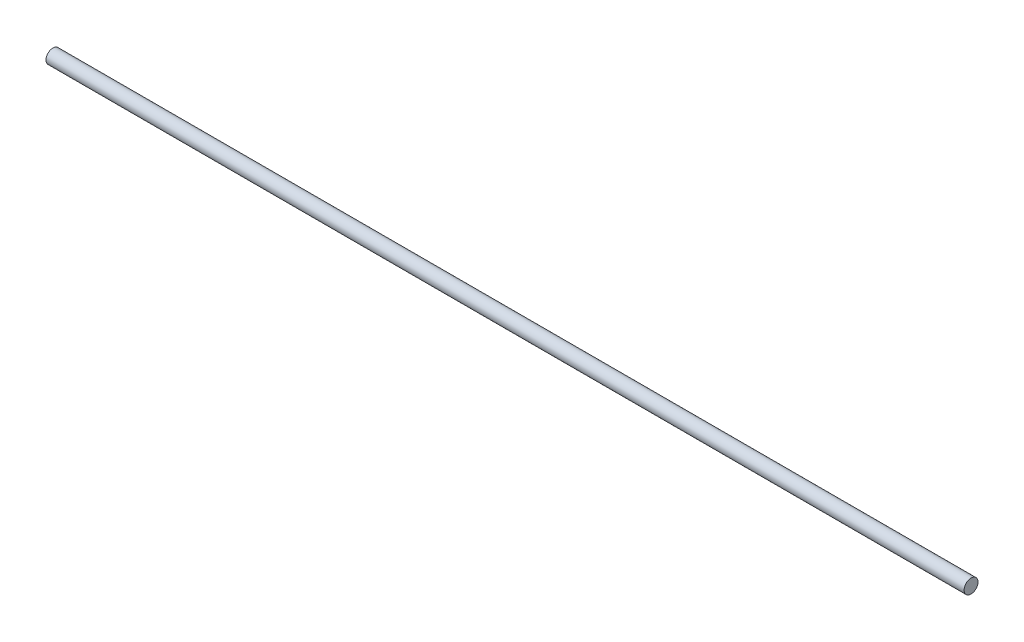
from build123d import *

# Parameters (mm, degrees)
BOSS_EXTRUDE1_START = -14.174338
SKETCH2_R           = 2
BOSS_EXTRUDE1_DEPTH = 263.888


with BuildPart() as part:
    # Sketch2 → Boss-Extrude1 (new body)
    with BuildSketch(Plane(origin=(0, 0, 0), x_dir=(0, 0, -1), z_dir=(1, 0, 0)).offset(BOSS_EXTRUDE1_START)):
        with Locations((0, 0.117111756)):
            Circle(SKETCH2_R)
    extrude(amount=-BOSS_EXTRUDE1_DEPTH)


solid = part.part
